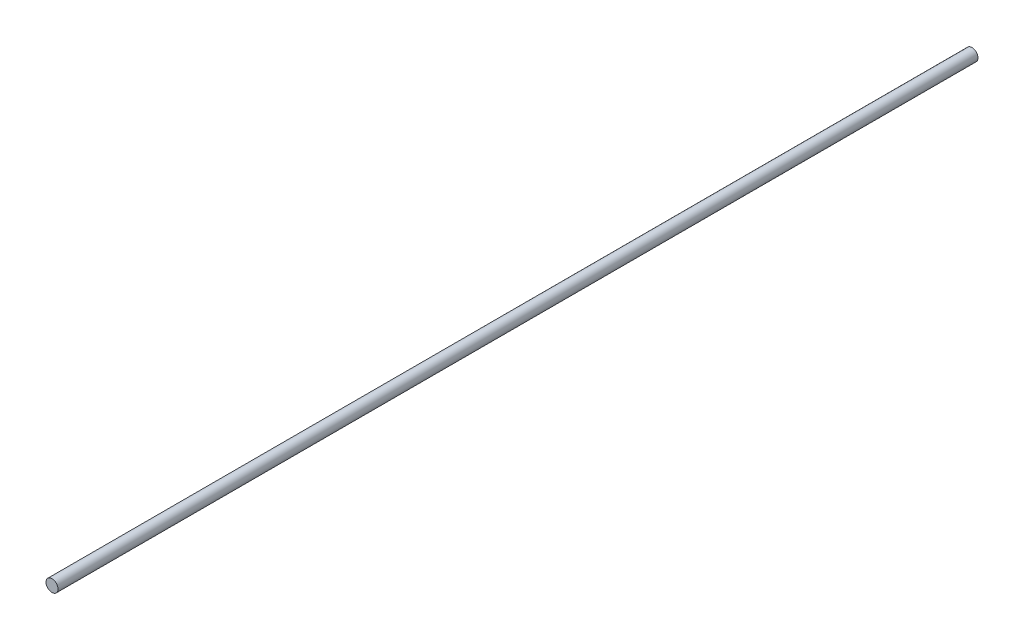
from build123d import *

# Parameters (mm, degrees)
SKETCH_1_R      = 13.05
EXTRUDE_1_DEPTH = 2000


with BuildPart() as part:
    # 草图1 → 凸台-拉伸1 (new body)
    with BuildSketch(Plane.XY):
        with Locations((-2.497576243, 4.492168382)):
            Circle(SKETCH_1_R)
    extrude(amount=EXTRUDE_1_DEPTH)


solid = part.part
